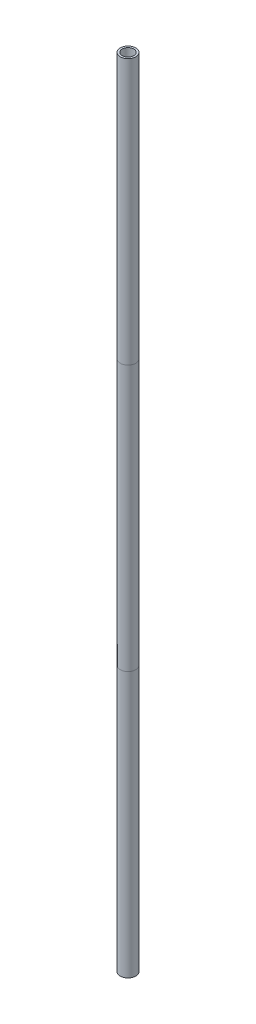
from build123d import *

# Parameters (mm, degrees)
SKETCH1_R                = 19.5
SKETCH1_R_2              = 14.5
BOSS_EXTRUDE1_DEPTH      = 2000
SPLIT1_SURFACE_1_1_BACK  = 2001.76
SPLIT1_SURFACE_1_1_DEPTH = 4003.52
SPLIT1_SURFACE_1_2_BACK  = 2001.76
SPLIT1_SURFACE_1_2_DEPTH = 4003.52
SPLIT1_SURFACE_2_3_BACK  = 2001.76
SPLIT1_SURFACE_2_3_DEPTH = 4003.52
SPLIT1_SURFACE_2_4_BACK  = 2001.76
SPLIT1_SURFACE_2_4_DEPTH = 4003.52


with BuildPart() as part:
    # Sketch1 → Boss-Extrude1 (new body)
    with BuildSketch(Plane(origin=(0, 0, 0), x_dir=(1, 0, 0), z_dir=(0, 1, 0))):
        with Locations(Location((0, 0, 0), (0, 0, 270))):
            Circle(SKETCH1_R)
        with Locations(Location((0, 0, 0), (0, 0, 270))):
            Circle(SKETCH1_R_2, mode=Mode.SUBTRACT)
    extrude(amount=BOSS_EXTRUDE1_DEPTH)


with BuildPart() as body_2:
    # Split1: the piece behind the surface
    add(part.part)
    # Split1 surface 1: a surface, the sketch's curves swept straight by 4003.52 mm
    with BuildLine(Plane.XY.offset(-SPLIT1_SURFACE_1_1_BACK), mode=Mode.PRIVATE) as split1_surface_1_1_path:
        Line((-19.5, 1333.333333333), (19.5, 1333.333333333))
    split1_surface_1_1 = Shell.extrude(split1_surface_1_1_path.wire(), (0 * SPLIT1_SURFACE_1_1_DEPTH, 0 * SPLIT1_SURFACE_1_1_DEPTH, 1 * SPLIT1_SURFACE_1_1_DEPTH))
    split(bisect_by=split1_surface_1_1, keep=Keep.BOTTOM)


with BuildPart() as part_1:
    add(part.part)

    # Split1: split by a surface, the side it looks to stays
    # Split1 surface 1: a surface, the sketch's curves swept straight by 4003.52 mm
    with BuildLine(Plane.XY.offset(-SPLIT1_SURFACE_1_2_BACK), mode=Mode.PRIVATE) as split1_surface_1_2_path:
        Line((-19.5, 1333.333333333), (19.5, 1333.333333333))
    split1_surface_1_2 = Shell.extrude(split1_surface_1_2_path.wire(), (0 * SPLIT1_SURFACE_1_2_DEPTH, 0 * SPLIT1_SURFACE_1_2_DEPTH, 1 * SPLIT1_SURFACE_1_2_DEPTH))
    split(bisect_by=split1_surface_1_2, keep=Keep.TOP)


with BuildPart() as body_3:
    # Split1 2 body 2: the piece behind the surface
    add(body_2.part)
    # Split1 surface 2: a surface, the sketch's curves swept straight by 4003.52 mm
    with BuildLine(Plane.XY.offset(-SPLIT1_SURFACE_2_3_BACK), mode=Mode.PRIVATE) as split1_surface_2_3_path:
        Line((-19.5, 666.666666667), (19.5, 666.666666667))
    split1_surface_2_3 = Shell.extrude(split1_surface_2_3_path.wire(), (0 * SPLIT1_SURFACE_2_3_DEPTH, 0 * SPLIT1_SURFACE_2_3_DEPTH, 1 * SPLIT1_SURFACE_2_3_DEPTH))
    split(bisect_by=split1_surface_2_3, keep=Keep.BOTTOM)


with BuildPart() as body_2_1:
    add(body_2.part)

    # Split1 2 body 2: split by a surface, the side it looks to stays
    # Split1 surface 2: a surface, the sketch's curves swept straight by 4003.52 mm
    with BuildLine(Plane.XY.offset(-SPLIT1_SURFACE_2_4_BACK), mode=Mode.PRIVATE) as split1_surface_2_4_path:
        Line((-19.5, 666.666666667), (19.5, 666.666666667))
    split1_surface_2_4 = Shell.extrude(split1_surface_2_4_path.wire(), (0 * SPLIT1_SURFACE_2_4_DEPTH, 0 * SPLIT1_SURFACE_2_4_DEPTH, 1 * SPLIT1_SURFACE_2_4_DEPTH))
    split(bisect_by=split1_surface_2_4, keep=Keep.TOP)


solid = Compound([part_1.part, body_3.part, body_2_1.part])
